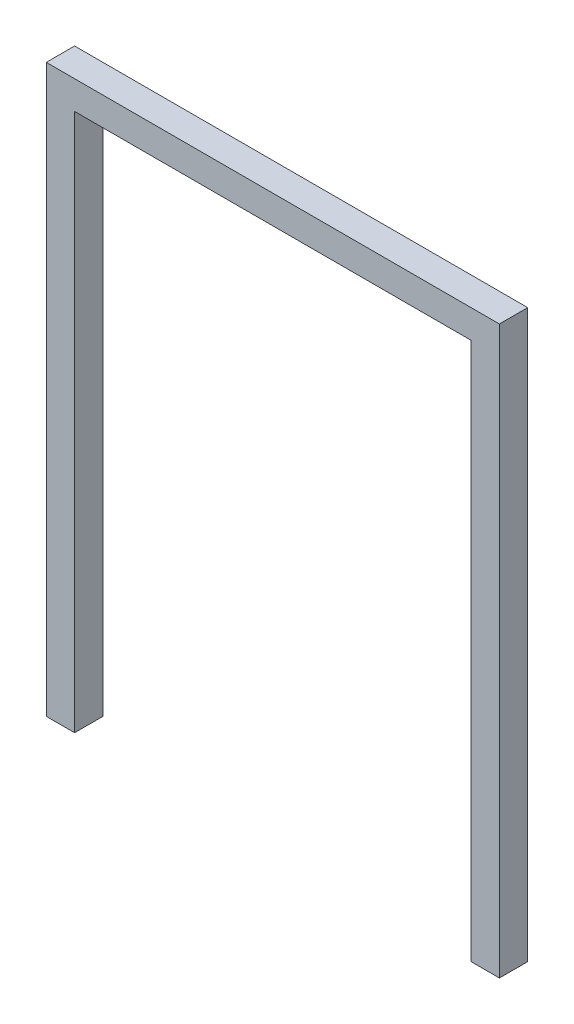
from build123d import *

# Parameters (mm, degrees)
BOSS_EXTRUDE1_DEPTH = 25.4


with BuildPart() as part:
    # Sketch2 → Boss-Extrude1 (new body)
    with BuildSketch(Plane.XY):
        Polygon((25.4, 482.6), (381, 482.6), (381, 25.4), (381, 0), (406.4, 0), (406.4, 508), (0, 508), (0, 0), (25.4, 0), (25.4, 25.4), align=None)
    extrude(amount=BOSS_EXTRUDE1_DEPTH)


solid = part.part
